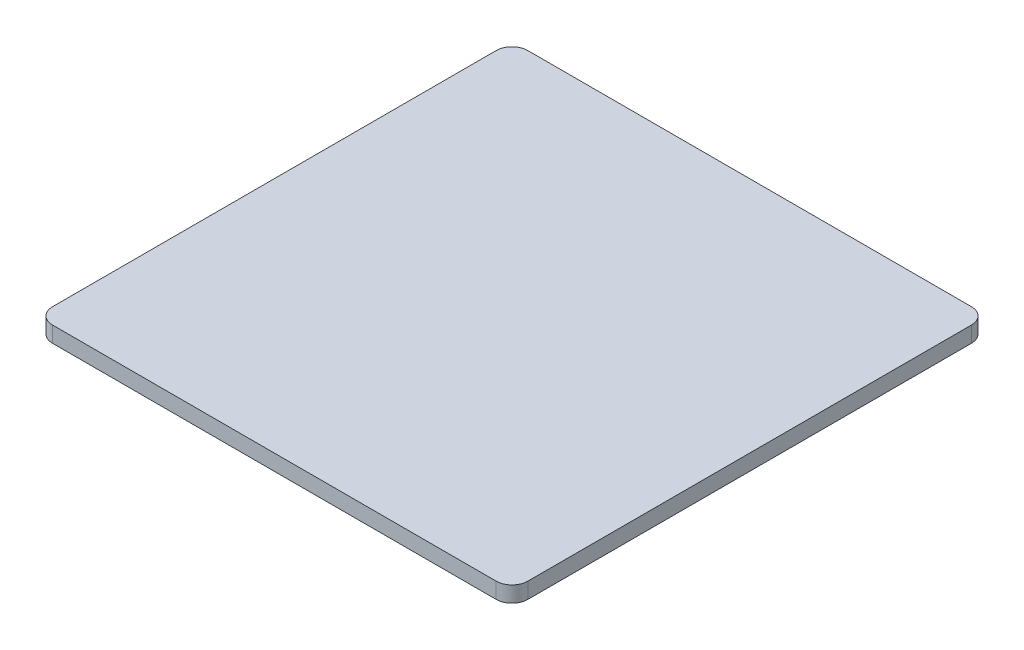
from build123d import *

# Parameters (mm, degrees)
BOSS_EXTRUDE1_DEPTH = 10


with BuildPart() as part:
    # Sketch1 → Boss-Extrude1 (new body)
    with BuildSketch(Plane(origin=(0, 0, 0), x_dir=(1, 0, 0), z_dir=(0, 1, 0))):
        with BuildLine():
            Line((140, 150), (-140, 150))
            ThreePointArc((-140, 150), (-147.071067812, 147.071067812), (-150, 140))
            Line((-150, 140), (-150, -140))
            ThreePointArc((-150, -140), (-147.071067812, -147.071067812), (-140, -150))
            Line((-140, -150), (140, -150))
            ThreePointArc((140, -150), (147.071067812, -147.071067812), (150, -140))
            Line((150, -140), (150, 140))
            ThreePointArc((150, 140), (147.071067812, 147.071067812), (140, 150))
        make_face()
    extrude(amount=BOSS_EXTRUDE1_DEPTH)


solid = part.part
